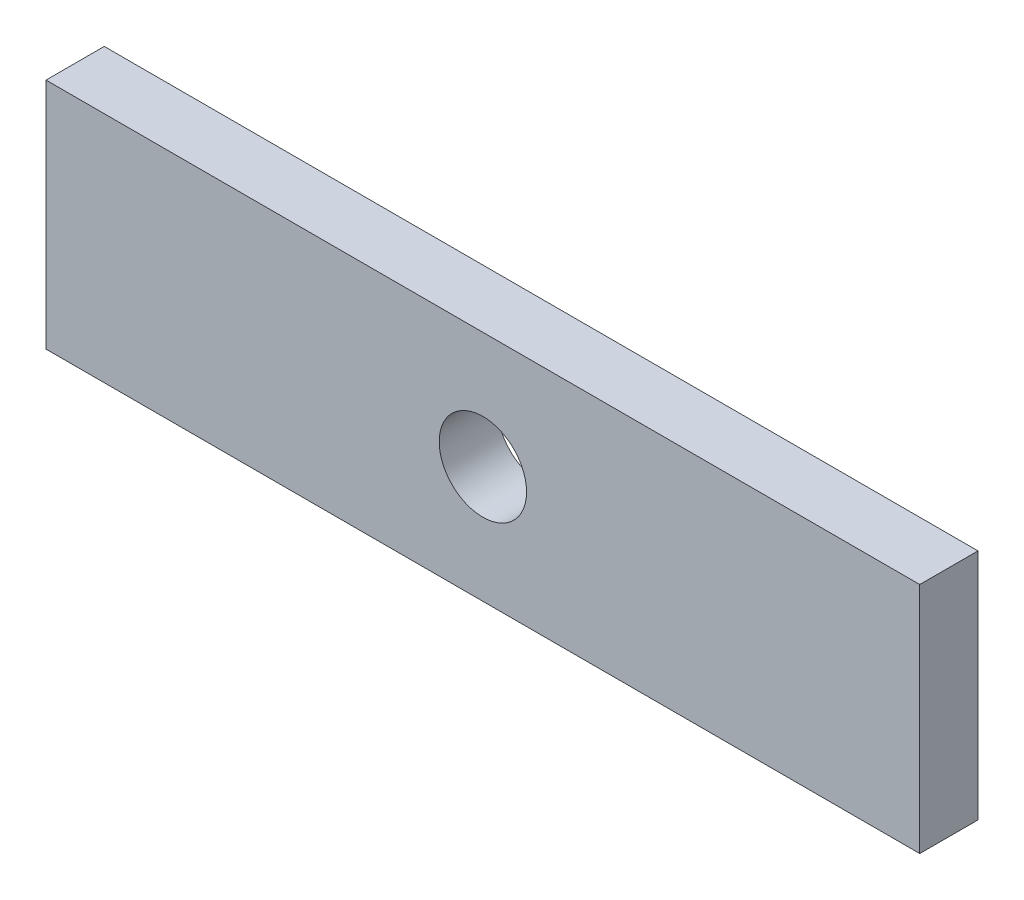
from build123d import *

# Parameters (mm, degrees)
CROQUIS1_W              = 150
CROQUIS1_H              = 40
CROQUIS1_R              = 7.5
SALIENTE_EXTRUIR1_DEPTH = 10


with BuildPart() as part:
    # Croquis1 → Saliente-Extruir1 (new body)
    with BuildSketch(Plane.XY):
        with Locations((75, 20)):
            Rectangle(CROQUIS1_W, CROQUIS1_H)
        with Locations((75, 20)):
            Circle(CROQUIS1_R, mode=Mode.SUBTRACT)
    extrude(amount=SALIENTE_EXTRUIR1_DEPTH)


solid = part.part
